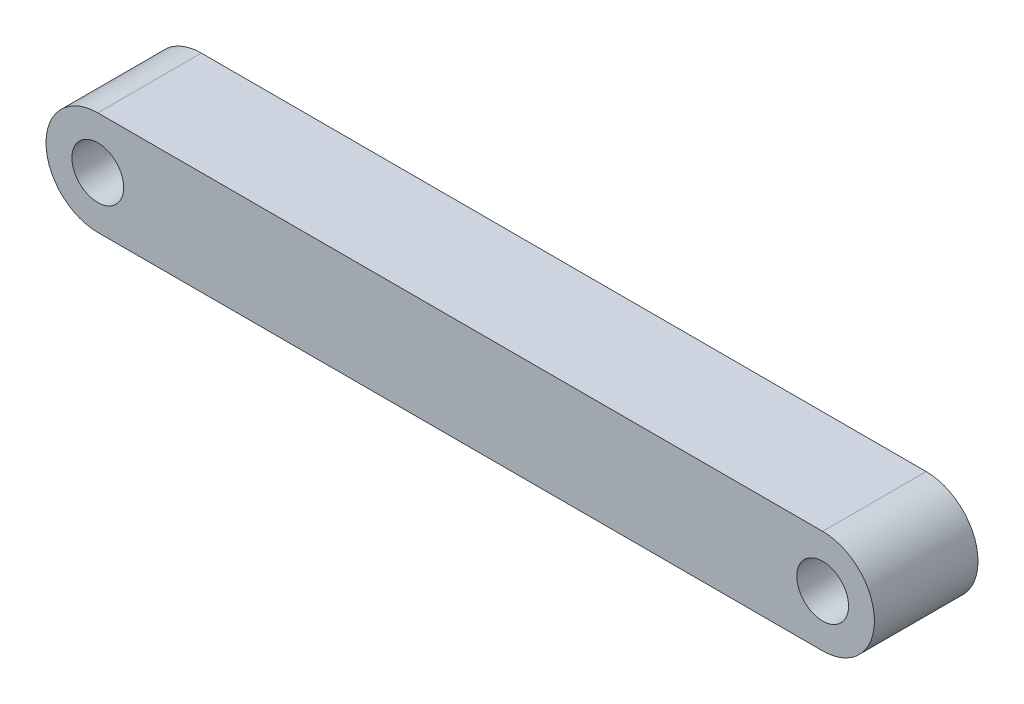
from build123d import *

# Parameters (mm, degrees)
SKETCH1_R           = 2.5
BOSS_EXTRUDE1_DEPTH = 10


with BuildPart() as part:
    # Sketch1 → Boss-Extrude1 (new body)
    with BuildSketch(Plane.XY):
        with BuildLine():
            Line((-35, 5), (35, 5))
            ThreePointArc((35, 5), (40, 0), (35, -5))
            Line((35, -5), (-35, -5))
            ThreePointArc((-35, -5), (-40, 0), (-35, 5))
        make_face()
        with Locations((-35, 0)):
            Circle(SKETCH1_R, mode=Mode.SUBTRACT)
        with Locations((35, 0)):
            Circle(SKETCH1_R, mode=Mode.SUBTRACT)
    extrude(amount=BOSS_EXTRUDE1_DEPTH)


solid = part.part
